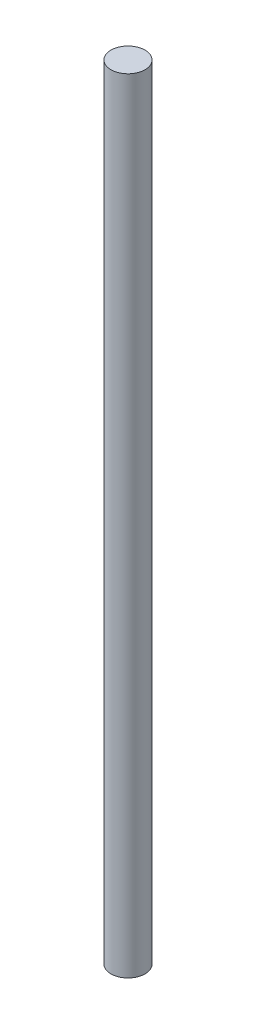
from build123d import *

# Parameters (mm, degrees)
SKETCH1_R           = 5
BOSS_EXTRUDE1_DEPTH = 230


with BuildPart() as part:
    # Sketch1 → Boss-Extrude1 (new body)
    with BuildSketch(Plane(origin=(0, 0, 0), x_dir=(1, 0, 0), z_dir=(0, 1, 0))):
        Circle(SKETCH1_R)
    extrude(amount=BOSS_EXTRUDE1_DEPTH)


solid = part.part
